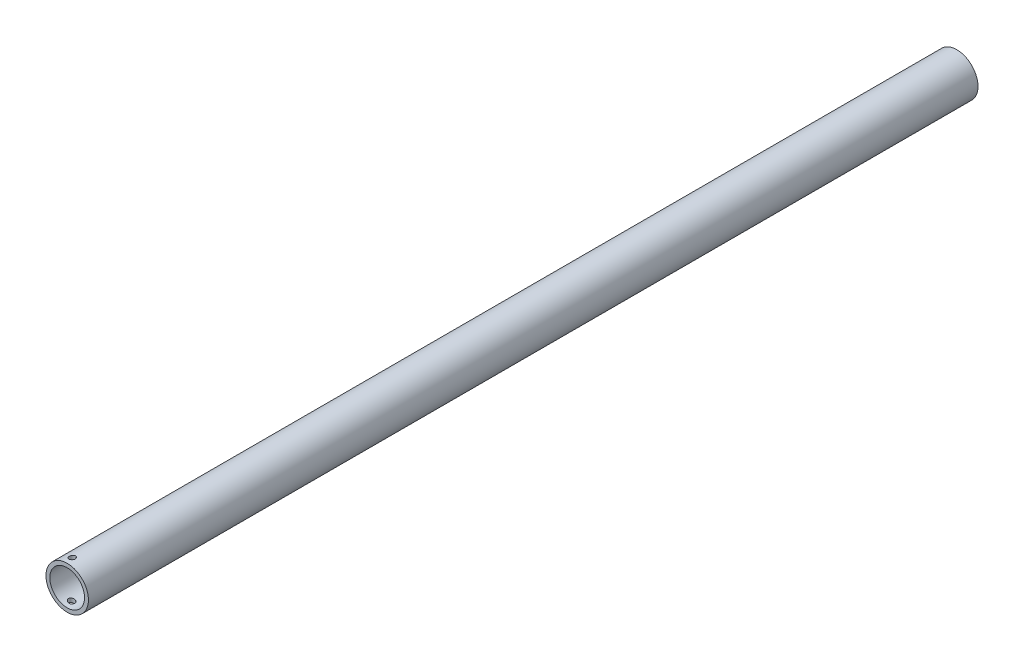
from build123d import *

# Parameters (mm, degrees)
SKETCH_1_R          = 11
SKETCH_1_R_2        = 9
EXTRUDE_1_DEPTH     = 461
SKETCH_2_R          = 1.6
CUT_EXTRUDE_1_DEPTH = 23.153615424


with BuildPart() as part:
    # 草图1 → 凸台-拉伸1 (new body)
    with BuildSketch(Plane.XY):
        Circle(SKETCH_1_R)
        Circle(SKETCH_1_R_2, mode=Mode.SUBTRACT)
    extrude(amount=EXTRUDE_1_DEPTH)

    # 草图2 → 切除-拉伸1 (cut, through all)
    with BuildSketch(Plane(origin=(0.154703347, 10.998912077, 0), x_dir=(0, 0, 1), z_dir=(0.014063941, 0.999901098, 0))):
        with Locations((457, -1.562338424)):
            Circle(SKETCH_2_R)
    extrude(amount=-CUT_EXTRUDE_1_DEPTH, mode=Mode.SUBTRACT)


solid = part.part
